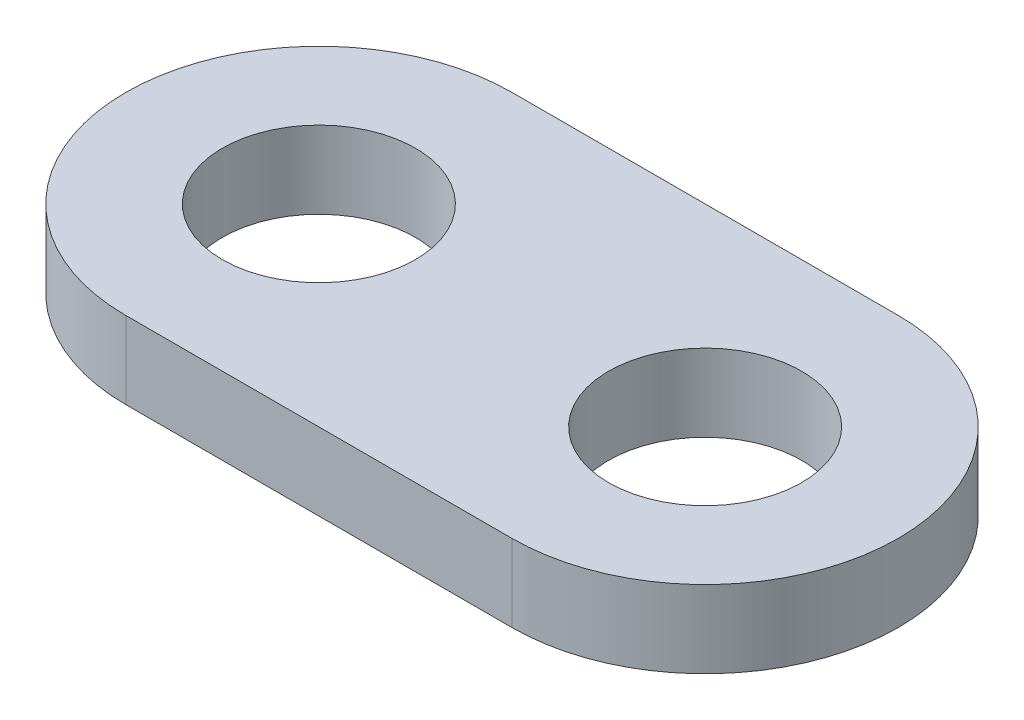
from build123d import *

# Parameters (mm, degrees)
SKETCH1_R           = 3.175
BOSS_EXTRUDE1_DEPTH = 2.54


with BuildPart() as part:
    # Sketch1 → Boss-Extrude1 (new body)
    with BuildSketch(Plane(origin=(0, 0, 0), x_dir=(1, 0, 0), z_dir=(0, 1, 0))):
        with BuildLine():
            Line((-6.35, 6.35), (6.35, 6.35))
            ThreePointArc((6.35, 6.35), (12.7, 0), (6.35, -6.35))
            Line((6.35, -6.35), (-6.35, -6.35))
            ThreePointArc((-6.35, -6.35), (-12.7, 0), (-6.35, 6.35))
        make_face()
        with Locations((-6.35, 0)):
            Circle(SKETCH1_R, mode=Mode.SUBTRACT)
        with Locations((6.35, 0)):
            Circle(SKETCH1_R, mode=Mode.SUBTRACT)
    extrude(amount=BOSS_EXTRUDE1_DEPTH)


solid = part.part
